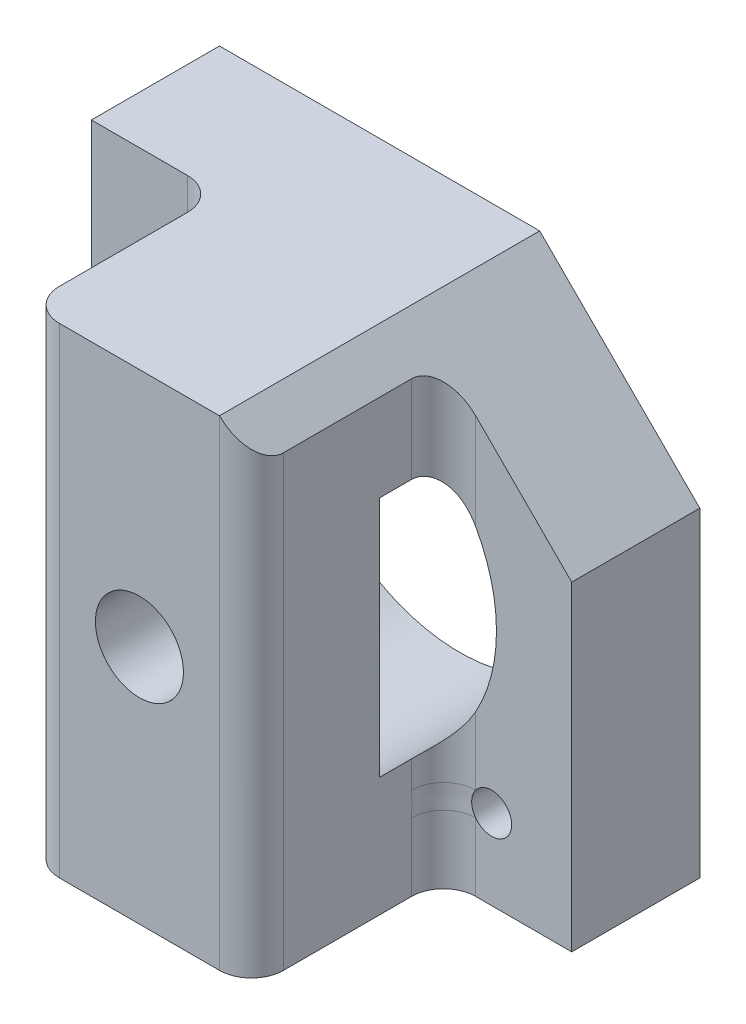
from build123d import *

# Parameters (mm, degrees)
SKETCH1_R          = 1.25
MAIN_DEPTH         = 20
SKETCH2_R          = 10.3
CENTRALHOLE_DEPTH  = 12
SKETCH5_R          = 2.75
SKETCH5_W          = 8
SKETCH5_H          = 30
CUT_EXTRUDE3_DEPTH = 12
FILLET1_R          = 2
SKETCH6_W          = 30
SKETCH6_H          = 30
CUT_EXTRUDE4_DEPTH = 21.0000001


with BuildPart() as part:
    # Sketch1 → Main (new body)
    with BuildSketch(Plane.XY):
        Polygon((-15, -15), (5, -15), (15, -5), (15, 15), (-15, 15), align=None)
        with Locations((-10, 10)):
            Circle(SKETCH1_R, mode=Mode.SUBTRACT)
        with Locations((10, 10)):
            Circle(SKETCH1_R, mode=Mode.SUBTRACT)
        with Locations((-10, -10)):
            Circle(SKETCH1_R, mode=Mode.SUBTRACT)
    extrude(amount=MAIN_DEPTH)

    # Sketch2 → CentralHole (cut)
    with BuildSketch(Plane.XY):
        Circle(SKETCH2_R)
    extrude(amount=CENTRALHOLE_DEPTH, mode=Mode.SUBTRACT)

    # Sketch5 → Cut-Extrude3 (cut)
    with BuildSketch(Plane.XY.offset(20)):
        Circle(SKETCH5_R)
        with Locations((11, 0)):
            Rectangle(SKETCH5_W, SKETCH5_H)
        with Locations((-11, 0)):
            Rectangle(SKETCH5_W, SKETCH5_H)
    extrude(amount=-CUT_EXTRUDE3_DEPTH, mode=Mode.SUBTRACT)

    # Fillet1
    fillet1_edges = [part.edges().sort_by_distance(p)[0] for p in [
        (-7, 0, 20),
        (7, 1, 20),
        (-7, 11.27789624, 8),
        (-7, -11.27789624, 8),
        (7, 11.27789624, 8),
        (7, -10.27789624, 8),
    ]]
    fillet(fillet1_edges, radius=FILLET1_R)


with BuildPart() as body_2:
    # Mirror1: mirrored copy
    add(part.part.mirror(Plane.ZX.offset(20)))


with BuildPart() as part_1:
    add(part.part)

    # Sketch6 → Cut-Extrude4 (cut, through all)
    with BuildSketch(Plane.XY.offset(20)):
        Rectangle(SKETCH6_W, SKETCH6_H)
    extrude(amount=-CUT_EXTRUDE4_DEPTH, mode=Mode.SUBTRACT)


solid = body_2.part
